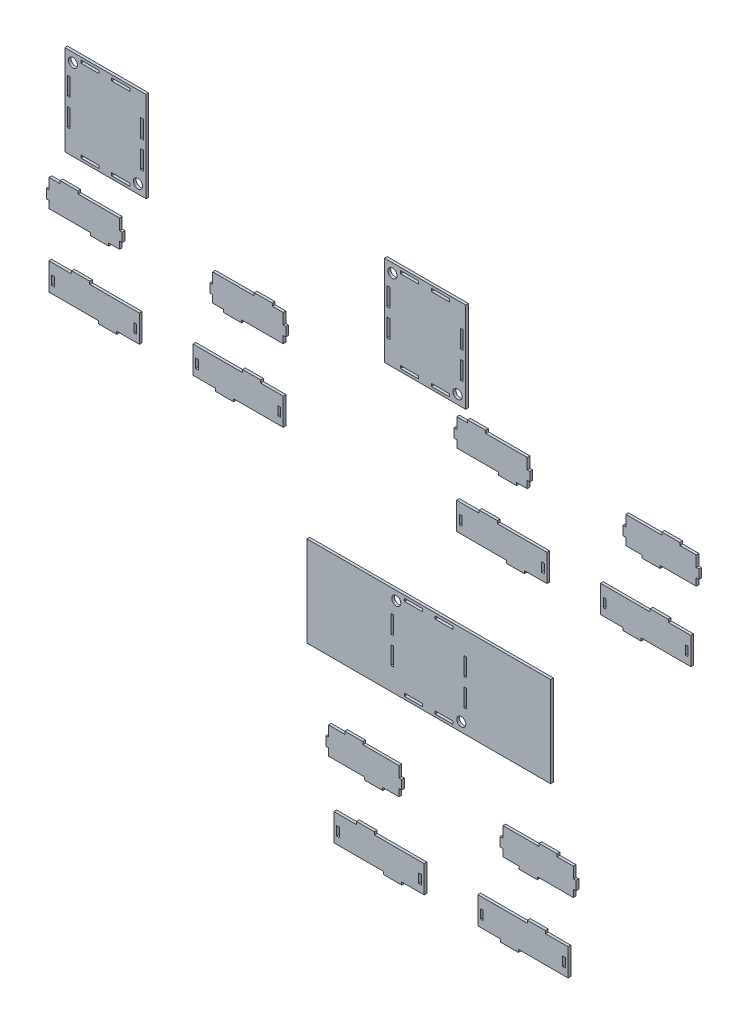
from build123d import *

# Parameters (mm, degrees)
EXTRUDE_1_DEPTH    = 3
SKETCH_1_W         = 3
SKETCH_1_H         = 10
EXTRUDE_1_2_DEPTH  = 3
EXTRUDE_1_3_DEPTH  = 3
SKETCH_1_W_2       = 90
SKETCH_1_H_2       = 100
SKETCH_1_R         = 5
SKETCH_1_H_3       = 20
SKETCH_1_W_3       = 20
SKETCH_1_H_4       = 3
EXTRUDE_1_4_DEPTH  = 3
EXTRUDE_1_5_DEPTH  = 3
EXTRUDE_1_6_DEPTH  = 3
EXTRUDE_1_7_DEPTH  = 3
EXTRUDE_1_8_DEPTH  = 3
EXTRUDE_1_9_DEPTH  = 3
EXTRUDE_1_10_DEPTH = 3
EXTRUDE_1_11_DEPTH = 3
EXTRUDE_1_12_DEPTH = 3
EXTRUDE_1_13_DEPTH = 3
EXTRUDE_1_14_DEPTH = 3
EXTRUDE_1_15_DEPTH = 3


with BuildPart() as part:
    # Эскиз1 → Бобышка-Вытянуть1 (new body)
    with BuildSketch(Plane.XY):
        Polygon((-251.165470976, 214.705049255), (-254.165470976, 214.705049255), (-254.165470976, 204.705049255), (-251.165470976, 204.705049255), (-251.165470976, 196.705049255), (-205.165470976, 196.705049255), (-205.165470976, 193.705049255), (-185.165470976, 193.705049255), (-185.165470976, 196.705049255), (-173.165470976, 196.705049255), (-173.165470976, 204.705049255), (-170.165470976, 204.705049255), (-170.165470976, 214.705049255), (-173.165470976, 214.705049255), (-173.165470976, 226.705049255), (-219.165470976, 226.705049255), (-219.165470976, 229.705049255), (-239.165470976, 229.705049255), (-239.165470976, 226.705049255), (-251.165470976, 226.705049255), align=None)
    extrude(amount=EXTRUDE_1_DEPTH)


with BuildPart() as body_2:
    # Эскиз1 → Extrude 1 2 (new body)
    with BuildSketch(Plane.XY):
        Polygon((-196.271811444, 116.59378358), (-196.271811444, 113.59378358), (-176.271811444, 113.59378358), (-176.271811444, 116.59378358), (-151.271811444, 116.59378358), (-151.271811444, 146.59378358), (-206.271811444, 146.59378358), (-206.271811444, 149.59378358), (-226.271811444, 149.59378358), (-226.271811444, 146.59378358), (-251.271811444, 146.59378358), (-251.271811444, 116.59378358), align=None)
        with Locations((-246.771811444, 129.59378358)):
            Rectangle(SKETCH_1_W, SKETCH_1_H, mode=Mode.SUBTRACT)
        with Locations((-155.771811444, 129.59378358)):
            Rectangle(SKETCH_1_W, SKETCH_1_H, mode=Mode.SUBTRACT)
    extrude(amount=EXTRUDE_1_2_DEPTH)


with BuildPart() as body_3:
    # Эскиз1 → Extrude 1 3 (new body)
    with BuildSketch(Plane.XY):
        Polygon((-58.028496911, 196.705049255), (-70.028496911, 196.705049255), (-70.028496911, 204.705049255), (-73.028496911, 204.705049255), (-73.028496911, 214.705049255), (-70.028496911, 214.705049255), (-70.028496911, 226.705049255), (-24.028496911, 226.705049255), (-24.028496911, 229.705049255), (-4.028496911, 229.705049255), (-4.028496911, 226.705049255), (7.971503089, 226.705049255), (7.971503089, 214.705049255), (10.971503089, 214.705049255), (10.971503089, 204.705049255), (7.971503089, 204.705049255), (7.971503089, 196.705049255), (-38.028496911, 196.705049255), (-38.028496911, 193.705049255), (-58.028496911, 193.705049255), align=None)
    extrude(amount=EXTRUDE_1_3_DEPTH)


with BuildPart() as body_4:
    # Эскиз1 → Extrude 1 4 (new body)
    with BuildSketch(Plane.XY):
        with Locations((-188.822696294, 309.879947413)):
            Rectangle(SKETCH_1_W_2, SKETCH_1_H_2)
        with Locations((-152.822696294, 269.879947413)):
            Circle(SKETCH_1_R, mode=Mode.SUBTRACT)
        with Locations((-224.822696294, 349.879947413)):
            Circle(SKETCH_1_R, mode=Mode.SUBTRACT)
        with Locations((-229.322696294, 294.879947413)):
            Rectangle(SKETCH_1_W, SKETCH_1_H_3, mode=Mode.SUBTRACT)
        with Locations((-205.822696294, 355.379947413)):
            Rectangle(SKETCH_1_W_3, SKETCH_1_H_4, mode=Mode.SUBTRACT)
        with Locations((-148.322696294, 294.879947413)):
            Rectangle(SKETCH_1_W, SKETCH_1_H_3, mode=Mode.SUBTRACT)
        with Locations((-205.822696294, 264.379947413)):
            Rectangle(SKETCH_1_W_3, SKETCH_1_H_4, mode=Mode.SUBTRACT)
        with Locations((-171.822696294, 355.379947413)):
            Rectangle(SKETCH_1_W_3, SKETCH_1_H_4, mode=Mode.SUBTRACT)
        with Locations((-148.322696294, 324.879947413)):
            Rectangle(SKETCH_1_W, SKETCH_1_H_3, mode=Mode.SUBTRACT)
        with Locations((-229.322696294, 324.879947413)):
            Rectangle(SKETCH_1_W, SKETCH_1_H_3, mode=Mode.SUBTRACT)
        with Locations((-171.822696294, 264.379947413)):
            Rectangle(SKETCH_1_W_3, SKETCH_1_H_4, mode=Mode.SUBTRACT)
    extrude(amount=EXTRUDE_1_4_DEPTH)


with BuildPart() as body_5:
    # Эскиз1 → Extrude 1 5 (new body)
    with BuildSketch(Plane.XY):
        Polygon((-36.922156443, 146.59378358), (-91.922156443, 146.59378358), (-91.922156443, 116.59378358), (-66.922156443, 116.59378358), (-66.922156443, 113.59378358), (-46.922156443, 113.59378358), (-46.922156443, 116.59378358), (8.077843557, 116.59378358), (8.077843557, 146.59378358), (-16.922156443, 146.59378358), (-16.922156443, 149.59378358), (-36.922156443, 149.59378358), align=None)
        with Locations((-87.422156443, 129.59378358)):
            Rectangle(SKETCH_1_W, SKETCH_1_H, mode=Mode.SUBTRACT)
        with Locations((3.577843557, 129.59378358)):
            Rectangle(SKETCH_1_W, SKETCH_1_H, mode=Mode.SUBTRACT)
    extrude(amount=EXTRUDE_1_5_DEPTH)


with BuildPart() as body_6:
    # Эскиз1 → Extrude 1 6 (new body)
    with BuildSketch(Plane.XY):
        with Locations((165.137211889, 284.937042664)):
            Rectangle(SKETCH_1_W_2, SKETCH_1_H_2)
        with Locations((201.137211889, 244.937042664)):
            Circle(SKETCH_1_R, mode=Mode.SUBTRACT)
        with Locations((129.137211889, 324.937042664)):
            Circle(SKETCH_1_R, mode=Mode.SUBTRACT)
        with Locations((124.637211889, 269.937042664)):
            Rectangle(SKETCH_1_W, SKETCH_1_H_3, mode=Mode.SUBTRACT)
        with Locations((148.137211889, 330.437042664)):
            Rectangle(SKETCH_1_W_3, SKETCH_1_H_4, mode=Mode.SUBTRACT)
        with Locations((205.637211889, 269.937042664)):
            Rectangle(SKETCH_1_W, SKETCH_1_H_3, mode=Mode.SUBTRACT)
        with Locations((148.137211889, 239.437042664)):
            Rectangle(SKETCH_1_W_3, SKETCH_1_H_4, mode=Mode.SUBTRACT)
        with Locations((182.137211889, 330.437042664)):
            Rectangle(SKETCH_1_W_3, SKETCH_1_H_4, mode=Mode.SUBTRACT)
        with Locations((205.637211889, 299.937042664)):
            Rectangle(SKETCH_1_W, SKETCH_1_H_3, mode=Mode.SUBTRACT)
        with Locations((124.637211889, 299.937042664)):
            Rectangle(SKETCH_1_W, SKETCH_1_H_3, mode=Mode.SUBTRACT)
        with Locations((182.137211889, 239.437042664)):
            Rectangle(SKETCH_1_W_3, SKETCH_1_H_4, mode=Mode.SUBTRACT)
    extrude(amount=EXTRUDE_1_6_DEPTH)


with BuildPart() as body_7:
    # Эскиз1 → Extrude 1 7 (new body)
    with BuildSketch(Plane.XY):
        Polygon((124.266684173, 22.861216451), (214.266684173, 22.861216451), (304.266684173, 22.861216451), (304.266684173, -77.138783549), (214.266684173, -77.138783549), (124.266684173, -77.138783549), (34.266684173, -77.138783549), (34.266684173, 22.861216451), align=None)
        with Locations((205.266684173, -67.138783549)):
            Circle(SKETCH_1_R, mode=Mode.SUBTRACT)
        with Locations((133.266684173, 12.861216451)):
            Circle(SKETCH_1_R, mode=Mode.SUBTRACT)
        with Locations((128.766684173, -42.138783549)):
            Rectangle(SKETCH_1_W, SKETCH_1_H_3, mode=Mode.SUBTRACT)
        with Locations((152.266684173, 18.361216451)):
            Rectangle(SKETCH_1_W_3, SKETCH_1_H_4, mode=Mode.SUBTRACT)
        with Locations((209.766684173, -42.138783549)):
            Rectangle(SKETCH_1_W, SKETCH_1_H_3, mode=Mode.SUBTRACT)
        with Locations((152.266684173, -72.638783549)):
            Rectangle(SKETCH_1_W_3, SKETCH_1_H_4, mode=Mode.SUBTRACT)
        with Locations((186.266684173, 18.361216451)):
            Rectangle(SKETCH_1_W_3, SKETCH_1_H_4, mode=Mode.SUBTRACT)
        with Locations((209.766684173, -12.138783549)):
            Rectangle(SKETCH_1_W, SKETCH_1_H_3, mode=Mode.SUBTRACT)
        with Locations((128.766684173, -12.138783549)):
            Rectangle(SKETCH_1_W, SKETCH_1_H_3, mode=Mode.SUBTRACT)
        with Locations((186.266684173, -72.638783549)):
            Rectangle(SKETCH_1_W_3, SKETCH_1_H_4, mode=Mode.SUBTRACT)
    extrude(amount=EXTRUDE_1_7_DEPTH)


with BuildPart() as body_8:
    # Эскиз1 → Extrude 1 8 (new body)
    with BuildSketch(Plane.XY):
        Polygon((200.250040897, 210.886801251), (197.250040897, 210.886801251), (197.250040897, 200.886801251), (200.250040897, 200.886801251), (200.250040897, 192.886801251), (246.250040897, 192.886801251), (246.250040897, 189.886801251), (266.250040897, 189.886801251), (266.250040897, 192.886801251), (278.250040897, 192.886801251), (278.250040897, 200.886801251), (281.250040897, 200.886801251), (281.250040897, 210.886801251), (278.250040897, 210.886801251), (278.250040897, 222.886801251), (232.250040897, 222.886801251), (232.250040897, 225.886801251), (212.250040897, 225.886801251), (212.250040897, 222.886801251), (200.250040897, 222.886801251), align=None)
    extrude(amount=EXTRUDE_1_8_DEPTH)


with BuildPart() as body_9:
    # Эскиз1 → Extrude 1 9 (new body)
    with BuildSketch(Plane.XY):
        Polygon((255.143700429, 112.775535577), (255.143700429, 109.775535577), (275.143700429, 109.775535577), (275.143700429, 112.775535577), (300.143700429, 112.775535577), (300.143700429, 142.775535577), (245.143700429, 142.775535577), (245.143700429, 145.775535577), (225.143700429, 145.775535577), (225.143700429, 142.775535577), (200.143700429, 142.775535577), (200.143700429, 112.775535577), align=None)
        with Locations((204.643700429, 125.775535577)):
            Rectangle(SKETCH_1_W, SKETCH_1_H, mode=Mode.SUBTRACT)
        with Locations((295.643700429, 125.775535577)):
            Rectangle(SKETCH_1_W, SKETCH_1_H, mode=Mode.SUBTRACT)
    extrude(amount=EXTRUDE_1_9_DEPTH)


with BuildPart() as body_10:
    # Эскиз1 → Extrude 1 10 (new body)
    with BuildSketch(Plane.XY):
        Polygon((405.387014962, 192.886801251), (387.387014962, 192.886801251), (387.387014962, 200.886801251), (384.387014962, 200.886801251), (384.387014962, 210.886801251), (387.387014962, 210.886801251), (387.387014962, 222.886801251), (427.387014962, 222.886801251), (427.387014962, 225.886801251), (447.387014962, 225.886801251), (447.387014962, 222.886801251), (465.387014962, 222.886801251), (465.387014962, 210.886801251), (468.387014962, 210.886801251), (468.387014962, 200.886801251), (465.387014962, 200.886801251), (465.387014962, 192.886801251), (425.387014962, 192.886801251), (425.387014962, 189.886801251), (405.387014962, 189.886801251), align=None)
    extrude(amount=EXTRUDE_1_10_DEPTH)


with BuildPart() as body_11:
    # Эскиз1 → Extrude 1 11 (new body)
    with BuildSketch(Plane.XY):
        Polygon((414.49335543, 142.775535577), (359.49335543, 142.775535577), (359.49335543, 112.775535577), (384.49335543, 112.775535577), (384.49335543, 109.775535577), (404.49335543, 109.775535577), (404.49335543, 112.775535577), (459.49335543, 112.775535577), (459.49335543, 142.775535577), (434.49335543, 142.775535577), (434.49335543, 145.775535577), (414.49335543, 145.775535577), align=None)
        with Locations((363.99335543, 125.775535577)):
            Rectangle(SKETCH_1_W, SKETCH_1_H, mode=Mode.SUBTRACT)
        with Locations((454.99335543, 125.775535577)):
            Rectangle(SKETCH_1_W, SKETCH_1_H, mode=Mode.SUBTRACT)
    extrude(amount=EXTRUDE_1_11_DEPTH)


with BuildPart() as body_12:
    # Эскиз1 → Extrude 1 12 (new body)
    with BuildSketch(Plane.XY):
        Polygon((58.2619165, -155.625503593), (55.2619165, -155.625503593), (55.2619165, -165.625503593), (58.2619165, -165.625503593), (58.2619165, -173.625503593), (98.2619165, -173.625503593), (98.2619165, -176.625503593), (118.2619165, -176.625503593), (118.2619165, -173.625503593), (136.2619165, -173.625503593), (136.2619165, -165.625503593), (139.2619165, -165.625503593), (139.2619165, -155.625503593), (136.2619165, -155.625503593), (136.2619165, -143.625503593), (96.2619165, -143.625503593), (96.2619165, -140.625503593), (76.2619165, -140.625503593), (76.2619165, -143.625503593), (58.2619165, -143.625503593), align=None)
    extrude(amount=EXTRUDE_1_12_DEPTH)


with BuildPart() as body_13:
    # Эскиз1 → Extrude 1 13 (new body)
    with BuildSketch(Plane.XY):
        Polygon((119.155576032, -253.736769267), (119.155576032, -256.736769267), (139.155576032, -256.736769267), (139.155576032, -253.736769267), (164.155576032, -253.736769267), (164.155576032, -223.736769267), (109.155576032, -223.736769267), (109.155576032, -220.736769267), (89.155576032, -220.736769267), (89.155576032, -223.736769267), (64.155576032, -223.736769267), (64.155576032, -253.736769267), align=None)
        with Locations((68.655576032, -240.736769267)):
            Rectangle(SKETCH_1_W, SKETCH_1_H, mode=Mode.SUBTRACT)
        with Locations((159.655576032, -240.736769267)):
            Rectangle(SKETCH_1_W, SKETCH_1_H, mode=Mode.SUBTRACT)
    extrude(amount=EXTRUDE_1_13_DEPTH)


with BuildPart() as body_14:
    # Эскиз1 → Extrude 1 14 (new body)
    with BuildSketch(Plane.XY):
        Polygon((269.398890565, -173.625503593), (251.398890565, -173.625503593), (251.398890565, -165.625503593), (248.398890565, -165.625503593), (248.398890565, -155.625503593), (251.398890565, -155.625503593), (251.398890565, -143.625503593), (291.398890565, -143.625503593), (291.398890565, -140.625503593), (311.398890565, -140.625503593), (311.398890565, -143.625503593), (329.398890565, -143.625503593), (329.398890565, -155.625503593), (332.398890565, -155.625503593), (332.398890565, -165.625503593), (329.398890565, -165.625503593), (329.398890565, -173.625503593), (289.398890565, -173.625503593), (289.398890565, -176.625503593), (269.398890565, -176.625503593), align=None)
    extrude(amount=EXTRUDE_1_14_DEPTH)


with BuildPart() as body_15:
    # Эскиз1 → Extrude 1 15 (new body)
    with BuildSketch(Plane.XY):
        Polygon((278.505231033, -223.736769267), (223.505231033, -223.736769267), (223.505231033, -253.736769267), (248.505231033, -253.736769267), (248.505231033, -256.736769267), (268.505231033, -256.736769267), (268.505231033, -253.736769267), (323.505231033, -253.736769267), (323.505231033, -223.736769267), (298.505231033, -223.736769267), (298.505231033, -220.736769267), (278.505231033, -220.736769267), align=None)
        with Locations((228.005231033, -240.736769267)):
            Rectangle(SKETCH_1_W, SKETCH_1_H, mode=Mode.SUBTRACT)
        with Locations((319.005231033, -240.736769267)):
            Rectangle(SKETCH_1_W, SKETCH_1_H, mode=Mode.SUBTRACT)
    extrude(amount=EXTRUDE_1_15_DEPTH)


solid = Compound([part.part, body_2.part, body_3.part, body_4.part, body_5.part, body_6.part, body_7.part, body_8.part, body_9.part, body_10.part, body_11.part, body_12.part, body_13.part, body_14.part, body_15.part])
